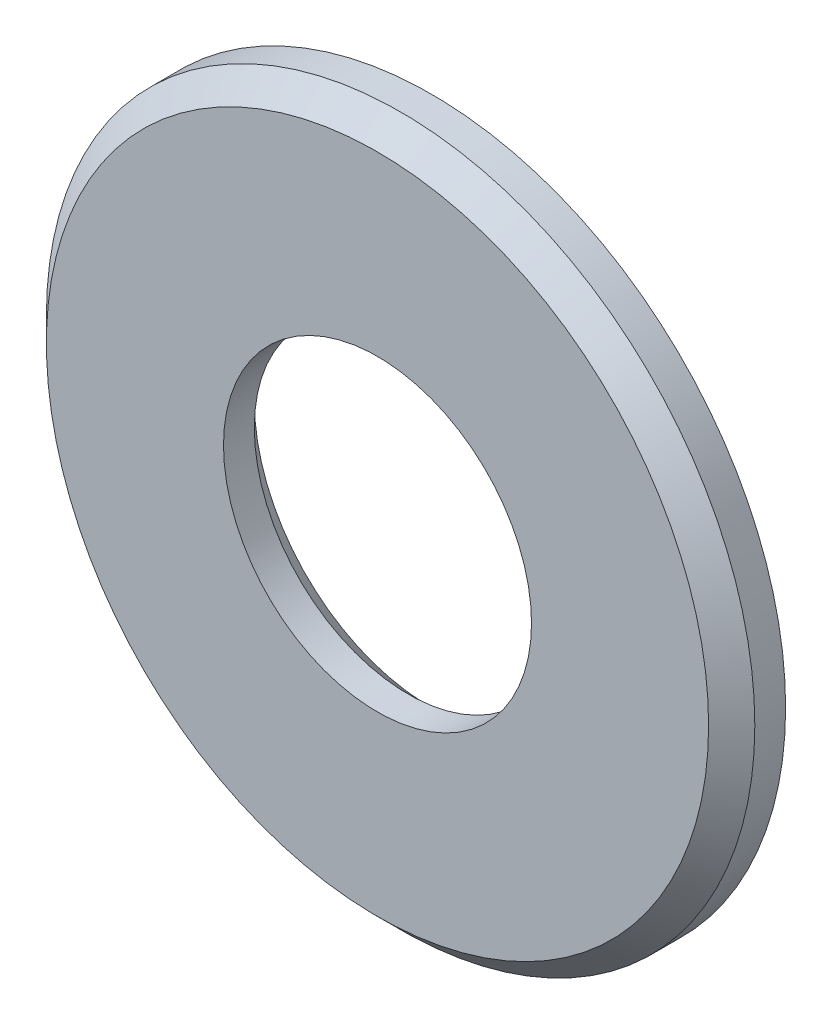
from build123d import *

# Parameters (mm, degrees)
ESQUISSE1_R        = 23
ESQUISSE1_R_2      = 10
BOSS_EXTRU_1_DEPTH = 3.5
CHANFREIN1_SIZE    = 1.5


with BuildPart() as part:
    # Esquisse1 → Boss.-Extru.1 (new body)
    with BuildSketch(Plane.XY):
        Circle(ESQUISSE1_R)
        Circle(ESQUISSE1_R_2, mode=Mode.SUBTRACT)
    extrude(amount=BOSS_EXTRU_1_DEPTH)

    # Chanfrein1
    chanfrein1_edges = [part.edges().sort_by_distance(p)[0] for p in [
        (-23, 0, 3.5),
        (-10, 0, 0),
    ]]
    chamfer(chanfrein1_edges, length=CHANFREIN1_SIZE)


solid = part.part
